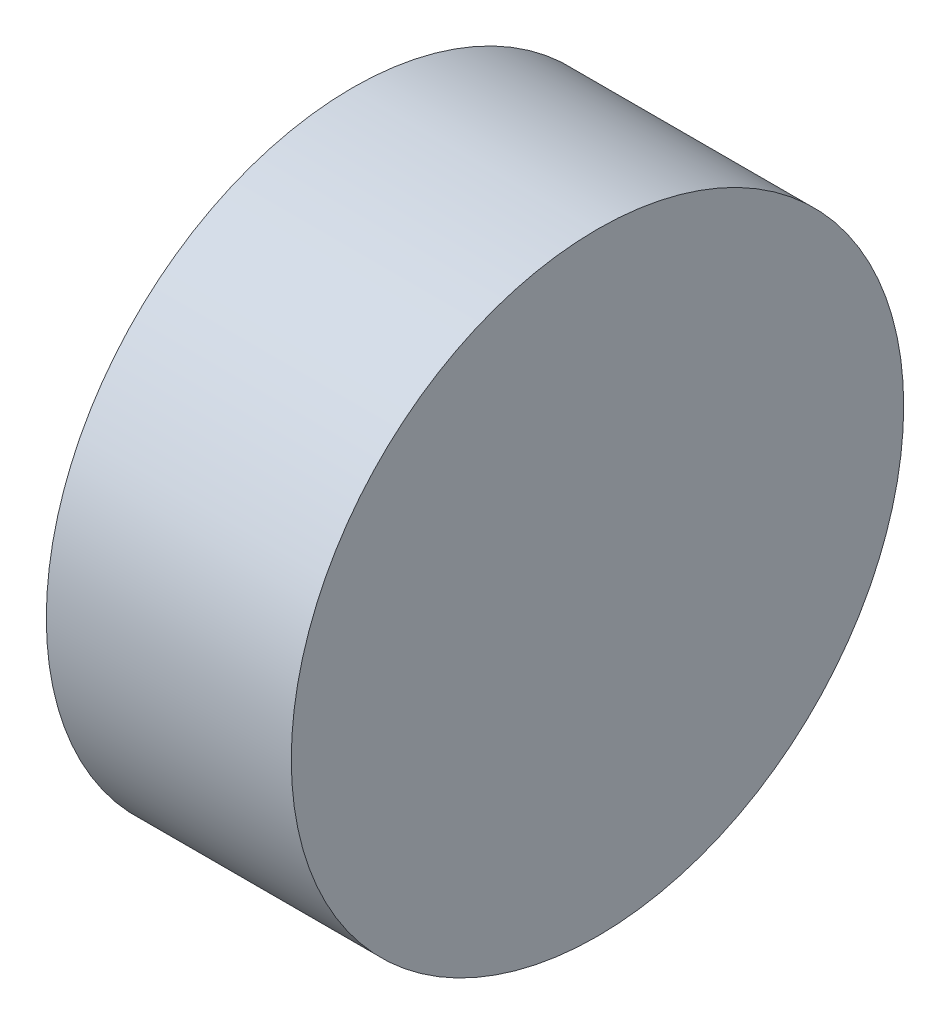
from build123d import *

# Parameters (mm, degrees)
SKETCH_1_W = 2
SKETCH_1_H = 2.5


with BuildPart() as part:
    # 草图1 → 旋转1 (revolve)
    with BuildSketch(Plane.XY, mode=Mode.PRIVATE) as revolve_1_sk:
        with Locations((53.031428099, 16.70863587)):
            Rectangle(SKETCH_1_W, SKETCH_1_H)
    revolve(revolve_1_sk.sketch.rotate(Axis((50.800160399, 15.45863587, 0), (1, 0, 0)), 90), axis=Axis((50.800160399, 15.45863587, 0), (1, 0, 0)))  # turned: the seam where the file's is


solid = part.part
